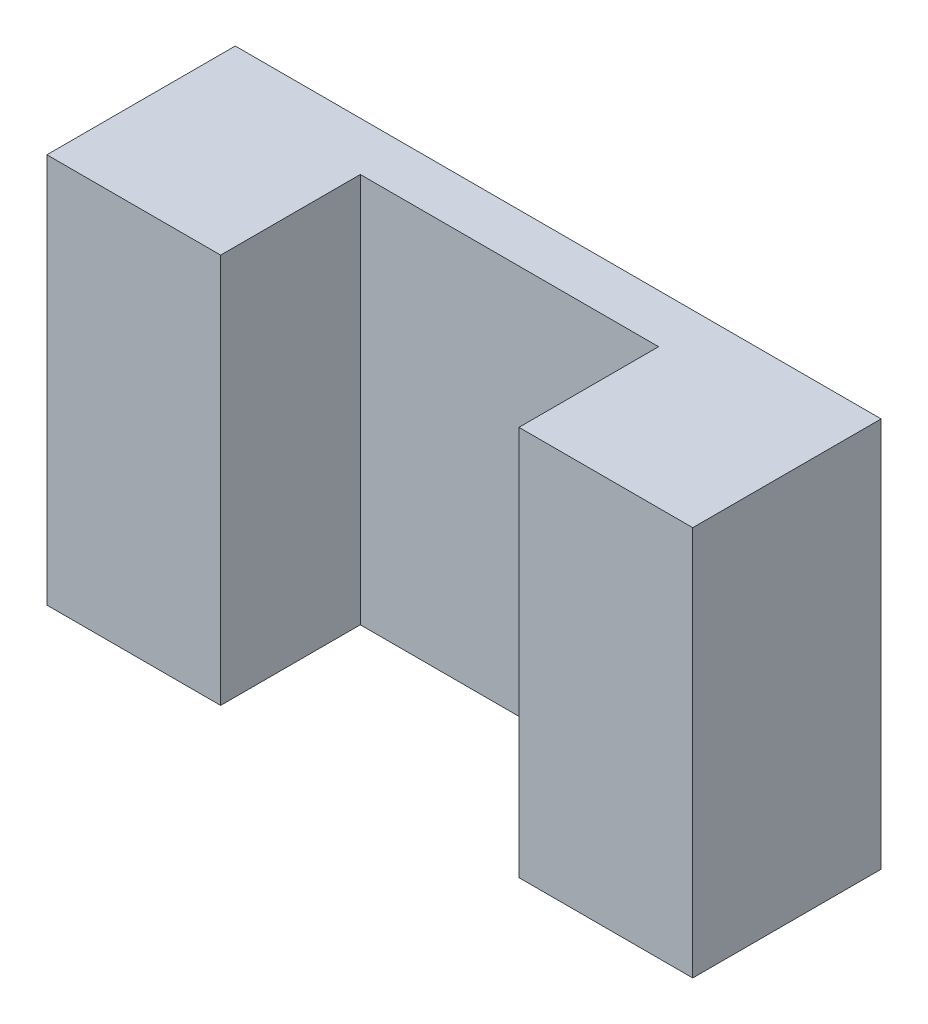
from build123d import *

# Parameters (mm, degrees)
SKETCH1_W           = 65.99377092
SKETCH1_H           = 39.85
BOSS_EXTRUDE1_DEPTH = 20
SKETCH2_W           = 30.48
SKETCH2_H           = 39.85
CUT_EXTRUDE1_DEPTH  = 15.02
SKETCH3_W           = 65.99377092
SKETCH3_H           = 39.85
CUT_EXTRUDE2_DEPTH  = 0.75


with BuildPart() as part:
    # Sketch1 → Boss-Extrude1 (new body)
    with BuildSketch(Plane.XY):
        Rectangle(SKETCH1_W, SKETCH1_H)
    extrude(amount=BOSS_EXTRUDE1_DEPTH)

    # Sketch2 → Cut-Extrude1 (cut)
    with BuildSketch(Plane.XY.offset(20)):
        Rectangle(SKETCH2_W, SKETCH2_H)
    extrude(amount=-CUT_EXTRUDE1_DEPTH, mode=Mode.SUBTRACT)

    # Sketch3 → Cut-Extrude2 (cut)
    with BuildSketch(Plane.XY.offset(20)):
        Rectangle(SKETCH3_W, SKETCH3_H)
    extrude(amount=-CUT_EXTRUDE2_DEPTH, mode=Mode.SUBTRACT)


solid = part.part
